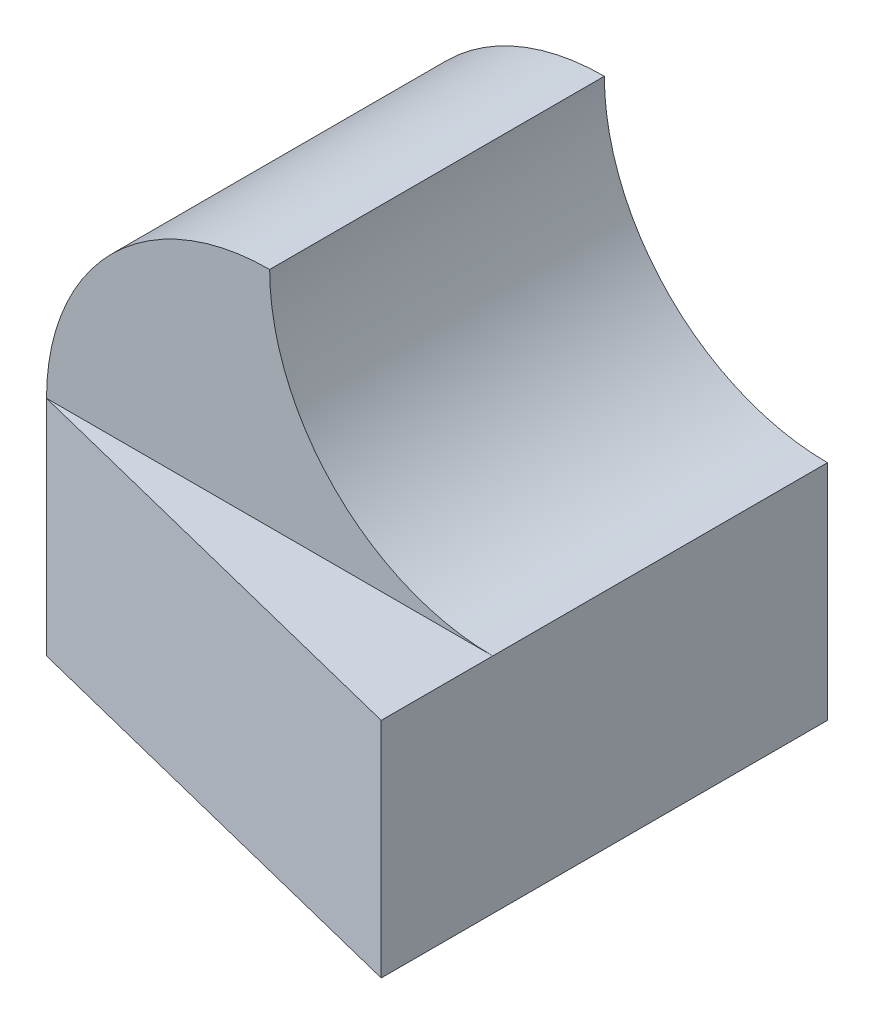
from build123d import *

# Parameters (mm, degrees)
BOSS_EXTRUDE1_DEPTH = 3
BOSS_EXTRUDE2_DEPTH = 2
CUT_EXTRUDE1_DEPTH  = 1


with BuildPart() as part:
    # Sketch1 → Boss-Extrude1 (new body)
    with BuildSketch(Plane.XY):
        with BuildLine():
            Line((0, 0), (4, 0))
            Line((4, 0), (4, 2))
            ThreePointArc((4, 2), (2.585786438, 2.585786438), (2, 4))
            ThreePointArc((2, 4), (0.585786438, 3.414213562), (0, 2))
            Line((0, 2), (0, 0))
        make_face()
    extrude(amount=BOSS_EXTRUDE1_DEPTH)

    # Sketch2 → Boss-Extrude2 (add)
    with BuildSketch(Plane.XZ):
        Polygon((0, 3), (4, 4), (4, 3), align=None)
    extrude(amount=-BOSS_EXTRUDE2_DEPTH)

    # Sketch4 → Cut-Extrude1 (cut)
    with BuildSketch(Plane(origin=(0, 0, 0), x_dir=(-1, 0, 0), z_dir=(0, 0, -1))):
        Polygon((-2, 0), (0, 2), (0, 0), align=None)
    extrude(amount=-CUT_EXTRUDE1_DEPTH, mode=Mode.SUBTRACT)


solid = part.part
